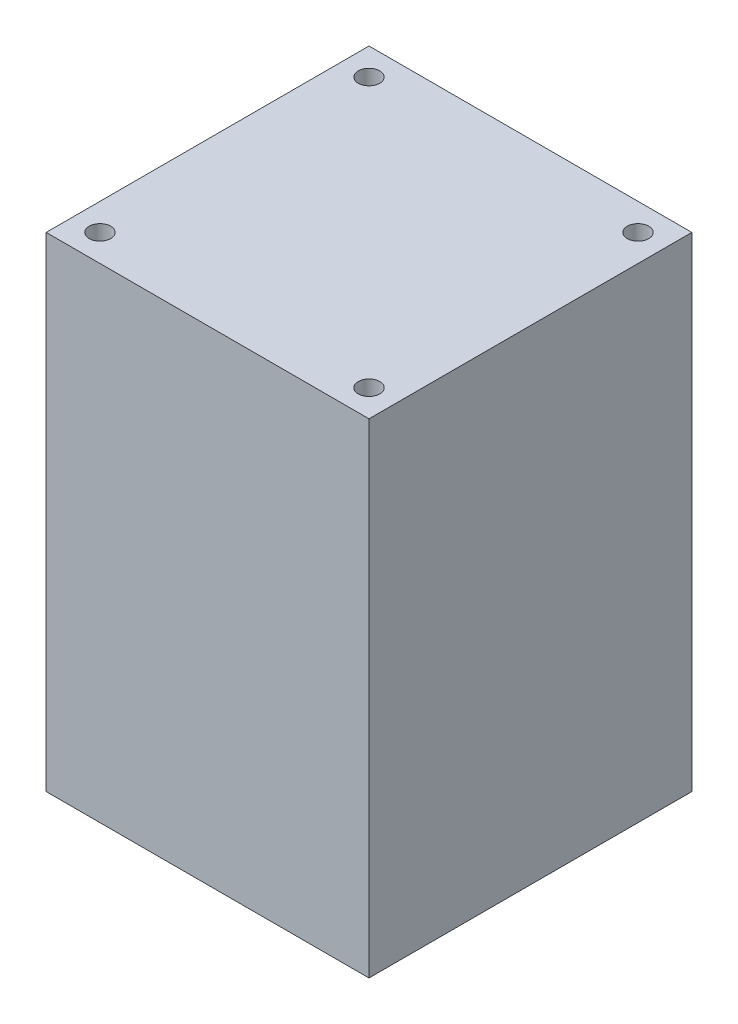
from build123d import *

# Parameters (mm, degrees)
SKETCH1_W               = 60
SKETCH1_H               = 60
BOSS_EXTRUDE1_DEPTH     = 90
SKETCH2_R               = 2
CUT_EXTRUDE1_DEPTH      = 10
MIRROR2_COPY_1_SKETCH_R = 2
MIRROR2_COPY_1_DEPTH    = 10


with BuildPart() as part:
    # Sketch1 → Boss-Extrude1 (new body)
    with BuildSketch(Plane(origin=(0, 0, 0), x_dir=(1, 0, 0), z_dir=(0, 1, 0))):
        Rectangle(SKETCH1_W, SKETCH1_H)
    extrude(amount=BOSS_EXTRUDE1_DEPTH)

    # Sketch2 → Cut-Extrude1 (cut)
    with BuildSketch(Plane(origin=(0, 90, 0), x_dir=(1, 0, 0), z_dir=(0, 1, 0))):
        with Locations((-25, 25)):
            Circle(SKETCH2_R)
    cut_extrude1 = extrude(amount=-CUT_EXTRUDE1_DEPTH, mode=Mode.SUBTRACT)

    # Mirror1: Cut-Extrude1 across plane
    add(cut_extrude1.mirror(Plane(origin=(0, 0, 0), x_dir=(0, 0, 1), z_dir=(1, 0, 0))), mode=Mode.SUBTRACT)

    # Mirror2: Cut-Extrude1 across plane
    add(cut_extrude1.mirror(Plane.XY), mode=Mode.SUBTRACT)

    # Mirror2 copy 1 sketch → Mirror2 copy 1 (cut)
    with BuildSketch(Plane(origin=(0, 90, 0), x_dir=(-1, 0, 0), z_dir=(0, 1, 0))):
        with Locations((-25, 25)):
            Circle(MIRROR2_COPY_1_SKETCH_R)
    extrude(amount=-MIRROR2_COPY_1_DEPTH, mode=Mode.SUBTRACT)


solid = part.part
